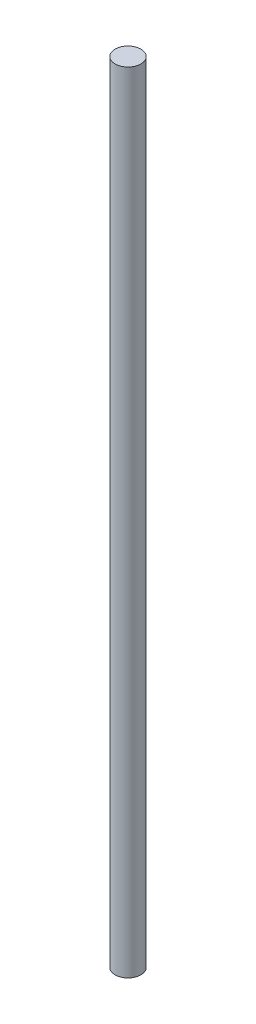
from build123d import *

# Parameters (mm, degrees)
ESBO_O1_R                = 2.45
RESSALTO_EXTRUS_O1_DEPTH = 150


with BuildPart() as part:
    # Esboço1 → Ressalto-extrusão1 (new body)
    with BuildSketch(Plane(origin=(0, 0, 0), x_dir=(1, 0, 0), z_dir=(0, 1, 0))):
        Circle(ESBO_O1_R)
    extrude(amount=RESSALTO_EXTRUS_O1_DEPTH)


solid = part.part
